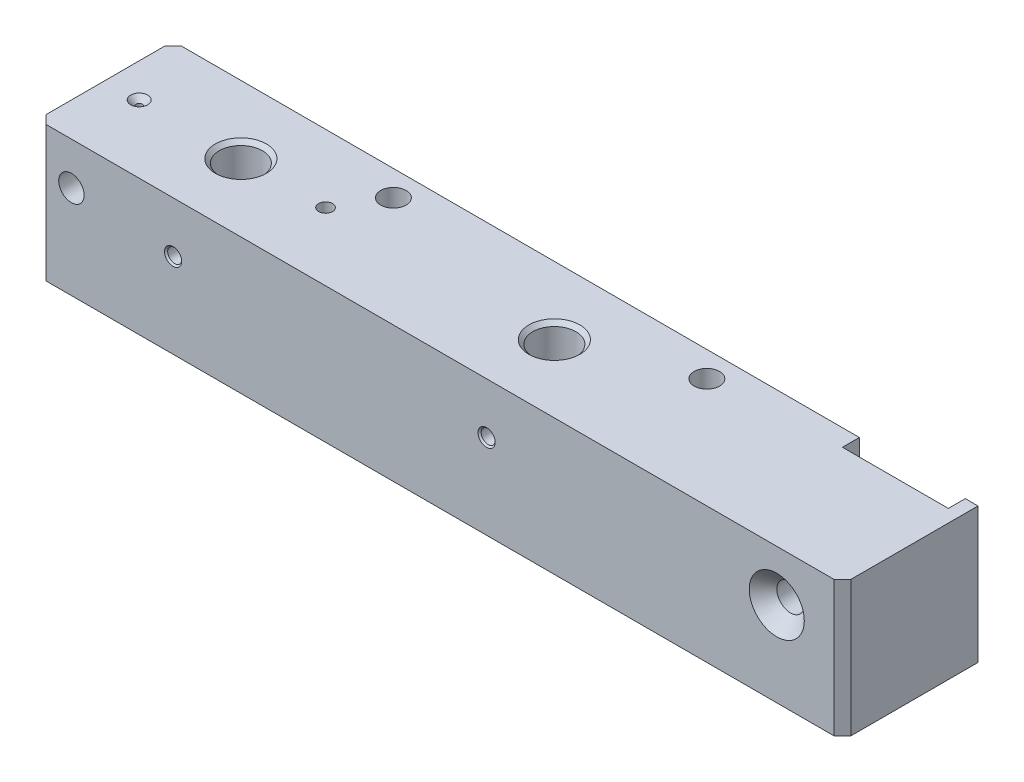
from build123d import *

# Parameters (mm, degrees)
SKETCH1_W                                            = 190
SKETCH1_H                                            = 32
BOSS_EXTRUDE1_DEPTH                                  = 16
CHAMFER1_SIZE                                        = 2
SKETCH3_W                                            = 25
SKETCH3_H                                            = 4
CUT_EXTRUDE1_DEPTH                                   = 33
M12_TAPPED_HOLE2_D                                   = 10.2
M12_TAPPED_HOLE2_DEPTH                               = 24
M12_TAPPED_HOLE2_CSINK_D                             = 12.05
M12_TAPPED_HOLE2_CSINK_ANGLE                         = 90
M12_TAPPED_HOLE2_TIP                                 = 3.064389157
M4_TAPPED_HOLE1_D                                    = 3.3
M4_TAPPED_HOLE1_DEPTH                                = 11.5
M4_TAPPED_HOLE1_CSINK_D                              = 4.05
M4_TAPPED_HOLE1_CSINK_ANGLE                          = 90
M4_TAPPED_HOLE1_TIP                                  = 0.991420021
SKETCH18_R                                           = 3
CUT_EXTRUDE2_DEPTH                                   = 33
CSK_FOR_M4_COUNTERSUNK_FLAT_HEAD_SCREW1_D            = 1.5
CSK_FOR_M4_COUNTERSUNK_FLAT_HEAD_SCREW1_DEPTH        = 10
CSK_FOR_M4_COUNTERSUNK_FLAT_HEAD_SCREW1_CSINK_D      = 4
CSK_FOR_M4_COUNTERSUNK_FLAT_HEAD_SCREW1_CSINK_ANGLE  = 90
CSK_FOR_M4_COUNTERSUNK_FLAT_HEAD_SCREW1_TIP          = 0.450645464
M4_TAPPED_HOLE3_D                                    = 3.3
M4_TAPPED_HOLE3_DEPTH                                = 16
M4_TAPPED_HOLE3_TIP                                  = 0.991420021
SKETCH25_R                                           = 3
CUT_EXTRUDE3_DEPTH                                   = 33
CSK_FOR_M10_COUNTERSUNK_FLAT_HEAD_SCREW1_D           = 6.5
CSK_FOR_M10_COUNTERSUNK_FLAT_HEAD_SCREW1_CSINK_D     = 13
CSK_FOR_M10_COUNTERSUNK_FLAT_HEAD_SCREW1_CSINK_ANGLE = 90


with BuildPart() as part:
    # Sketch1 → Boss-Extrude1 (new body, symmetric)
    with BuildSketch(Plane.XY):
        Rectangle(SKETCH1_W, SKETCH1_H)
    extrude(amount=BOSS_EXTRUDE1_DEPTH, both=True)

    # Chamfer1
    chamfer1_edges = [part.edges().sort_by_distance(p)[0] for p in [
        (-95, 0, 16),
        (95, 0, 16),
        (-95, 0, -16),
    ]]
    chamfer(chamfer1_edges, length=CHAMFER1_SIZE)

    # Sketch3 → Cut-Extrude1 (cut, through all)
    with BuildSketch(Plane(origin=(0, 16, 0), x_dir=(1, 0, 0), z_dir=(0, 1, 0))):
        with Locations((79.5, 14)):
            Rectangle(SKETCH3_W, SKETCH3_H)
    extrude(amount=-CUT_EXTRUDE1_DEPTH, mode=Mode.SUBTRACT)

    # M12 Tapped Hole2
    with Locations(Plane(origin=(0, 16, 0), x_dir=(1, 0, 0), z_dir=(0, 1, 0))):
        with Locations((-63, 0), (11, 0)):
            CounterSinkHole(M12_TAPPED_HOLE2_D / 2, M12_TAPPED_HOLE2_CSINK_D / 2, depth=M12_TAPPED_HOLE2_DEPTH, counter_sink_angle=M12_TAPPED_HOLE2_CSINK_ANGLE)
            with Locations((0, 0, -(M12_TAPPED_HOLE2_DEPTH + M12_TAPPED_HOLE2_TIP / 2))):  # 118° drill point
                Cone(0, M12_TAPPED_HOLE2_D / 2, M12_TAPPED_HOLE2_TIP, mode=Mode.SUBTRACT)

    # M4 Tapped Hole1
    with Locations(Plane.XY.offset(16)):
        with Locations((-63, 4), (11, 4)):
            CounterSinkHole(M4_TAPPED_HOLE1_D / 2, M4_TAPPED_HOLE1_CSINK_D / 2, depth=M4_TAPPED_HOLE1_DEPTH, counter_sink_angle=M4_TAPPED_HOLE1_CSINK_ANGLE)
            with Locations((0, 0, -(M4_TAPPED_HOLE1_DEPTH + M4_TAPPED_HOLE1_TIP / 2))):  # 118° drill point
                Cone(0, M4_TAPPED_HOLE1_D / 2, M4_TAPPED_HOLE1_TIP, mode=Mode.SUBTRACT)

    # Sketch18 → Cut-Extrude2 (cut, through all)
    with BuildSketch(Plane.XY.offset(16)):
        with Locations((-87, 6)):
            Circle(SKETCH18_R)
    extrude(amount=-CUT_EXTRUDE2_DEPTH, mode=Mode.SUBTRACT)

    # CSK for M4 Countersunk Flat Head Screw1
    with Locations(Plane(origin=(0, 16, 0), x_dir=(1, 0, 0), z_dir=(0, 1, 0))):
        with Locations((-87, 0)):
            CounterSinkHole(CSK_FOR_M4_COUNTERSUNK_FLAT_HEAD_SCREW1_D / 2, CSK_FOR_M4_COUNTERSUNK_FLAT_HEAD_SCREW1_CSINK_D / 2, depth=CSK_FOR_M4_COUNTERSUNK_FLAT_HEAD_SCREW1_DEPTH, counter_sink_angle=CSK_FOR_M4_COUNTERSUNK_FLAT_HEAD_SCREW1_CSINK_ANGLE)
            with Locations((0, 0, -(CSK_FOR_M4_COUNTERSUNK_FLAT_HEAD_SCREW1_DEPTH + CSK_FOR_M4_COUNTERSUNK_FLAT_HEAD_SCREW1_TIP / 2))):  # 118° drill point
                Cone(0, CSK_FOR_M4_COUNTERSUNK_FLAT_HEAD_SCREW1_D / 2, CSK_FOR_M4_COUNTERSUNK_FLAT_HEAD_SCREW1_TIP, mode=Mode.SUBTRACT)

    # M4 Tapped Hole3
    with Locations(Plane(origin=(0, 16, 0), x_dir=(1, 0, 0), z_dir=(0, 1, 0))):
        with Locations((-43, 0)):
            Hole(M4_TAPPED_HOLE3_D / 2, depth=M4_TAPPED_HOLE3_DEPTH)
            with Locations((0, 0, -(M4_TAPPED_HOLE3_DEPTH + M4_TAPPED_HOLE3_TIP / 2))):  # 118° drill point
                Cone(0, M4_TAPPED_HOLE3_D / 2, M4_TAPPED_HOLE3_TIP, mode=Mode.SUBTRACT)

    # Sketch25 → Cut-Extrude3 (cut, through all)
    with BuildSketch(Plane(origin=(0, 16, 0), x_dir=(1, 0, 0), z_dir=(0, 1, 0))):
        with Locations((-37, 10)):
            Circle(SKETCH25_R)
        with Locations((37, 10)):
            Circle(SKETCH25_R)
    extrude(amount=-CUT_EXTRUDE3_DEPTH, mode=Mode.SUBTRACT)

    # CSK for M10 Countersunk Flat Head Screw1 (through all)
    with Locations(Plane.XY.offset(16)):
        with Locations((79.5, 4)):
            CounterSinkHole(CSK_FOR_M10_COUNTERSUNK_FLAT_HEAD_SCREW1_D / 2, CSK_FOR_M10_COUNTERSUNK_FLAT_HEAD_SCREW1_CSINK_D / 2, counter_sink_angle=CSK_FOR_M10_COUNTERSUNK_FLAT_HEAD_SCREW1_CSINK_ANGLE)


solid = part.part
